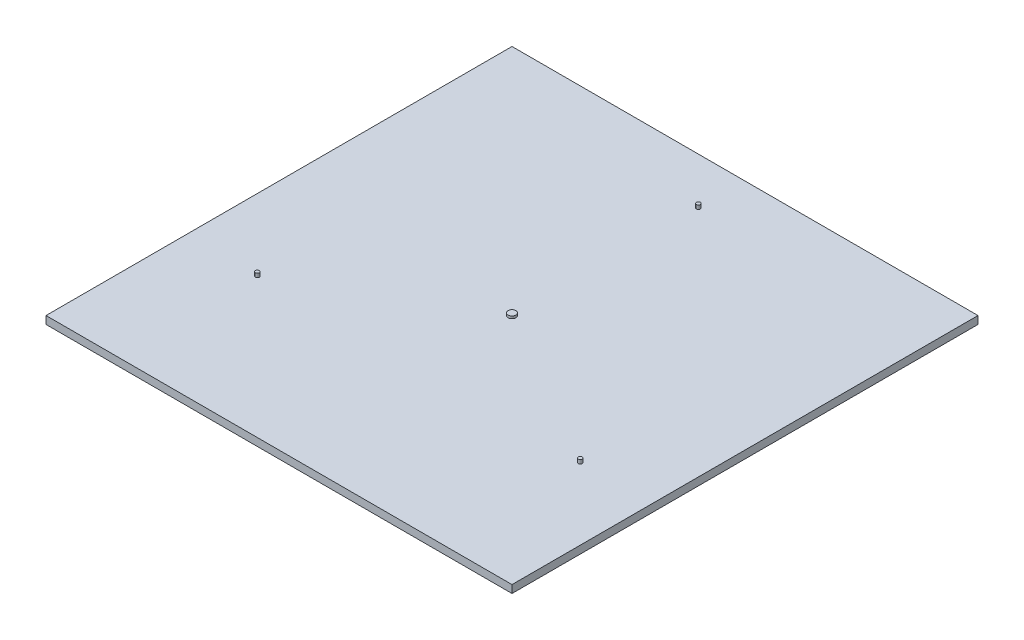
from build123d import *

# Parameters (mm, degrees)
SKETCH_2_W      = 600
SKETCH_2_H      = 600
EXTRUDE_1_DEPTH = 10
SKETCH_3_R      = 2.5
EXTRUDE_2_DEPTH = 5
SKETCH_4_R      = 5
EXTRUDE_3_DEPTH = 3


with BuildPart() as part:
    # 草图2 → 凸台-拉伸1 (new body)
    with BuildSketch(Plane(origin=(0, 0, 0), x_dir=(1, 0, 0), z_dir=(0, 1, 0))):
        Rectangle(SKETCH_2_W, SKETCH_2_H)
    extrude(amount=EXTRUDE_1_DEPTH)

    # 草图3 → 凸台-拉伸2 (add)
    with BuildSketch(Plane(origin=(0, 10, 0), x_dir=(1, 0, 0), z_dir=(0, 1, 0))):
        with Locations((0, 240)):
            Circle(SKETCH_3_R)
        with Locations((-207.846096908, -120)):
            Circle(SKETCH_3_R)
        with Locations((207.846096908, -120)):
            Circle(SKETCH_3_R)
    extrude(amount=EXTRUDE_2_DEPTH)

    # 草图4 → 凸台-拉伸3 (add)
    with BuildSketch(Plane(origin=(0, 10, 0), x_dir=(1, 0, 0), z_dir=(0, 1, 0))):
        Circle(SKETCH_4_R)
    extrude(amount=EXTRUDE_3_DEPTH)


solid = part.part
